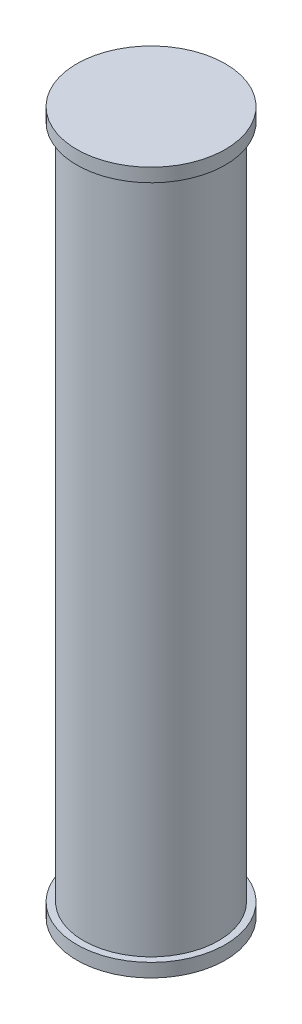
from build123d import *

# Parameters (mm, degrees)
SKETCH1_R           = 1.27
BOSS_EXTRUDE1_DEPTH = 6.35
SKETCH2_R           = 1.397
BOSS_EXTRUDE2_DEPTH = 0.254


with BuildPart() as part:
    # Sketch1 → Boss-Extrude1 (new body, symmetric)
    with BuildSketch(Plane(origin=(0, 0, 0), x_dir=(1, 0, 0), z_dir=(0, 1, 0))):
        Circle(SKETCH1_R)
    extrude(amount=BOSS_EXTRUDE1_DEPTH, both=True)

    # Sketch2 → Boss-Extrude2 (add)
    with BuildSketch(Plane.XZ.offset(6.35)):
        Circle(SKETCH2_R)
    boss_extrude2 = extrude(amount=BOSS_EXTRUDE2_DEPTH)

    # Mirror1: Boss-Extrude2 across plane
    add(boss_extrude2.mirror(Plane.ZX))


solid = part.part
